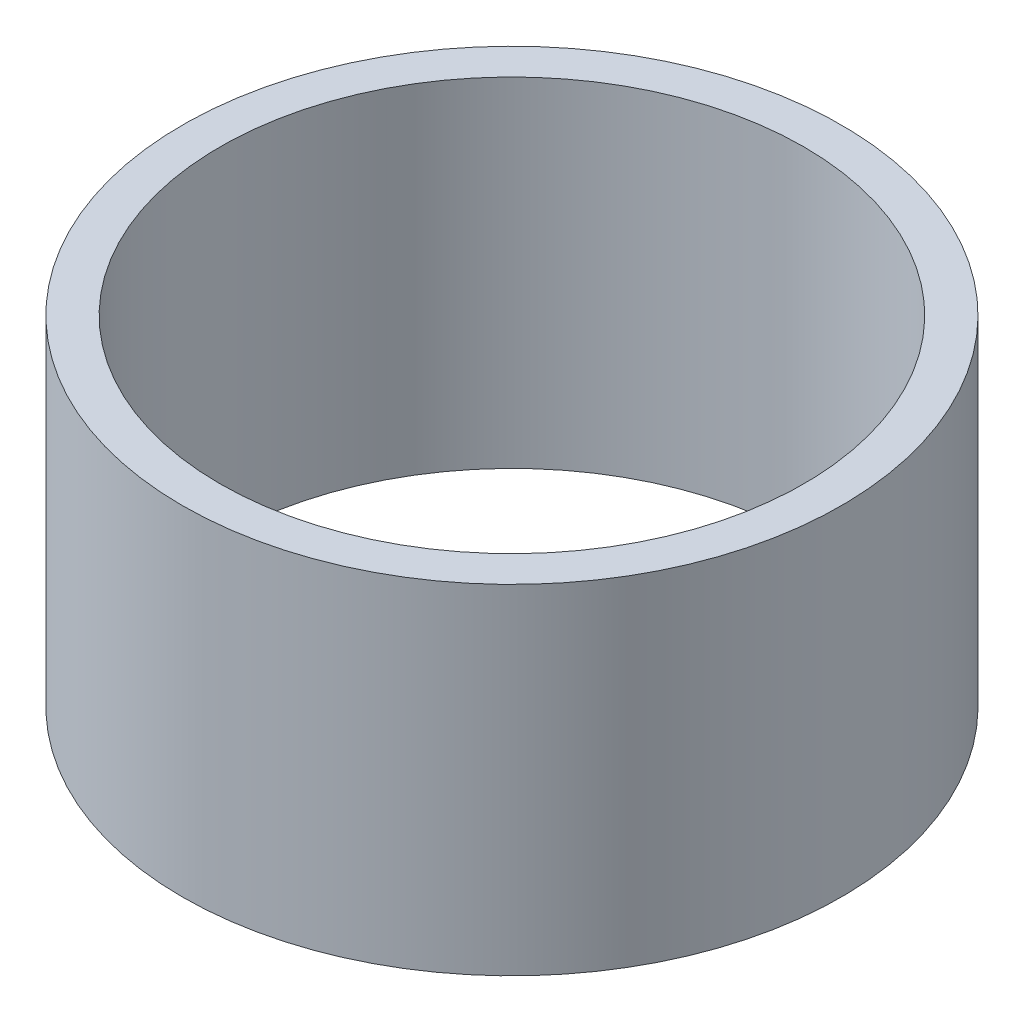
from build123d import *

# Parameters (mm, degrees)
SKETCH1_R           = 17.5
BOSS_EXTRUDE1_DEPTH = 18
SKETCH2_R           = 15.5
CUT_EXTRUDE1_DEPTH  = 18


with BuildPart() as part:
    # Sketch1 → Boss-Extrude1 (new body)
    with BuildSketch(Plane(origin=(0, 0, 0), x_dir=(1, 0, 0), z_dir=(0, 1, 0))):
        Circle(SKETCH1_R)
    extrude(amount=BOSS_EXTRUDE1_DEPTH)

    # Sketch2 → Cut-Extrude1 (cut)
    with BuildSketch(Plane(origin=(0, 18, 0), x_dir=(1, 0, 0), z_dir=(0, 1, 0))):
        Circle(SKETCH2_R)
    extrude(amount=-CUT_EXTRUDE1_DEPTH, mode=Mode.SUBTRACT)


solid = part.part
